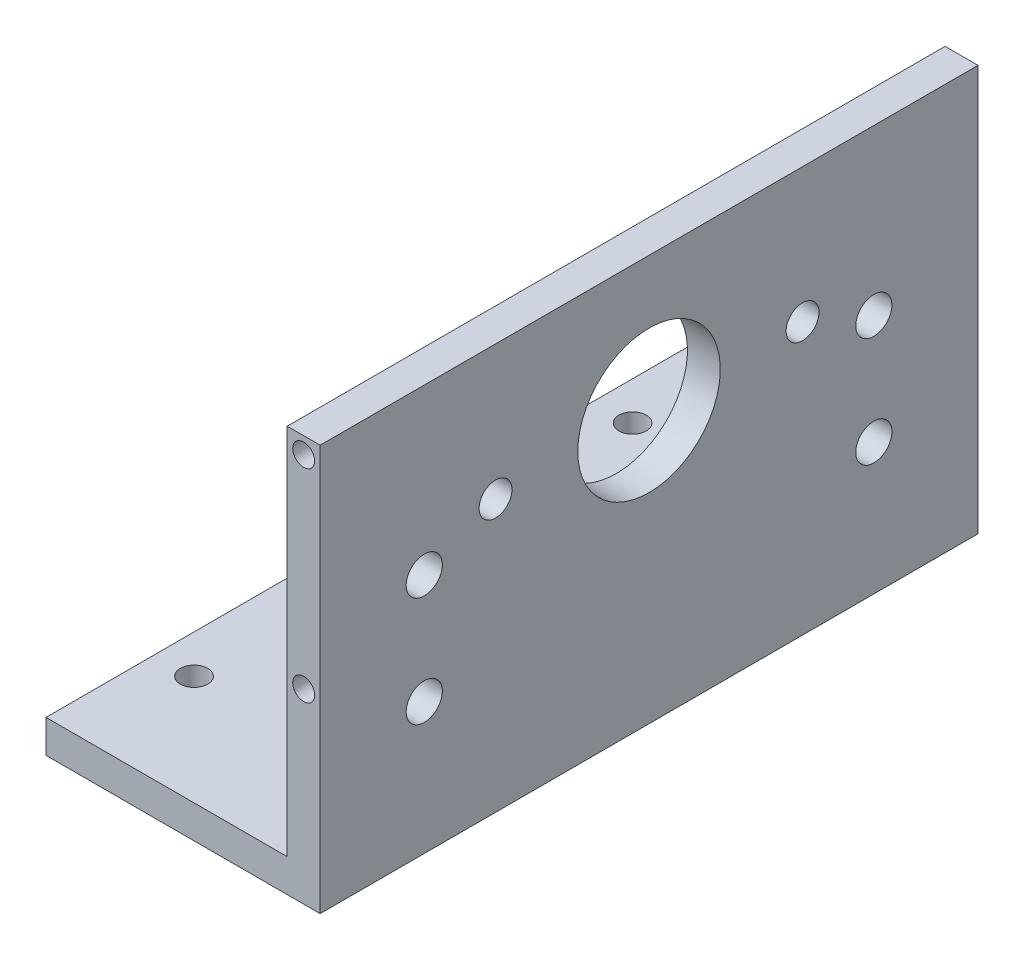
from build123d import *

# Parameters (mm, degrees)
SKETCH_1_W          = 44
SKETCH_1_H          = 120
EXTRUDE_1_DEPTH     = 6
SKETCH_1_3_W        = 6
SKETCH_1_3_H        = 120
EXTRUDE_2_DEPTH     = 74
SKETCH_2_R          = 13
SKETCH_2_R_2        = 3
CUT_EXTRUDE_1_DEPTH = 105.938076979
SKETCH_3_R          = 2.5
CUT_EXTRUDE_2_DEPTH = 10
SKETCH_4_R          = 2
CUT_EXTRUDE_3_DEPTH = 20
SKETCH_5_R          = 3.3
CUT_EXTRUDE_4_DEPTH = 10


with BuildPart() as part:
    # 草图1 → 凸台-拉伸1 (new body)
    with BuildSketch(Plane(origin=(0, 0, 0), x_dir=(1, 0, 0), z_dir=(0, 1, 0))):
        with Locations((-3, 0)):
            Rectangle(SKETCH_1_W, SKETCH_1_H)
    extrude(amount=EXTRUDE_1_DEPTH)

    # 草图1<3> → 凸台-拉伸2 (add)
    with BuildSketch(Plane(origin=(0, 0, 0), x_dir=(1, 0, 0), z_dir=(0, 1, 0))):
        with Locations((22, 0)):
            Rectangle(SKETCH_1_3_W, SKETCH_1_3_H)
    extrude(amount=EXTRUDE_2_DEPTH)

    # 草图2 → 切除-拉伸1 (cut, through all)
    with BuildSketch(Plane.ZY.offset(-19)):
        with Locations((0, 49.5)):
            Circle(SKETCH_2_R)
        with Locations((-28, 49.5)):
            Circle(SKETCH_2_R_2)
        with Locations((28, 49.5)):
            Circle(SKETCH_2_R_2)
    extrude(amount=-CUT_EXTRUDE_1_DEPTH, mode=Mode.SUBTRACT)

    # 草图3 → 切除-拉伸2 (cut)
    with BuildSketch(Plane(origin=(0, 6, 0), x_dir=(1, 0, 0), z_dir=(0, 1, 0))):
        with Locations((-18, 40)):
            Circle(SKETCH_3_R)
        with Locations((12, 40)):
            Circle(SKETCH_3_R)
        with Locations((-18, -40)):
            Circle(SKETCH_3_R)
        with Locations((12, -40)):
            Circle(SKETCH_3_R)
    extrude(amount=-CUT_EXTRUDE_2_DEPTH, mode=Mode.SUBTRACT)

    # 草图4 → 切除-拉伸3 (cut)
    with BuildSketch(Plane(origin=(0, 0, -60), x_dir=(-1, 0, 0), z_dir=(0, 0, -1))):
        with Locations((-22, 34)):
            Circle(SKETCH_4_R)
        with Locations((-22, 71)):
            Circle(SKETCH_4_R)
    cut_extrude_3 = extrude(amount=-CUT_EXTRUDE_3_DEPTH, mode=Mode.SUBTRACT)

    # 镜向1: 切除-拉伸3 across plane
    add(cut_extrude_3.mirror(Plane(origin=(0, 0, 0), x_dir=(1, 0, 0), z_dir=(0, 0, -1))), mode=Mode.SUBTRACT)

    # 草图5 → 切除-拉伸4 (cut)
    with BuildSketch(Plane(origin=(25, 0, 0), x_dir=(0, 0, -1), z_dir=(1, 0, 0))):
        with Locations((41, 44)):
            Circle(SKETCH_5_R)
        with Locations((41, 24)):
            Circle(SKETCH_5_R)
        with Locations((-41, 24)):
            Circle(SKETCH_5_R)
        with Locations((-41, 44)):
            Circle(SKETCH_5_R)
    extrude(amount=-CUT_EXTRUDE_4_DEPTH, mode=Mode.SUBTRACT)


solid = part.part
